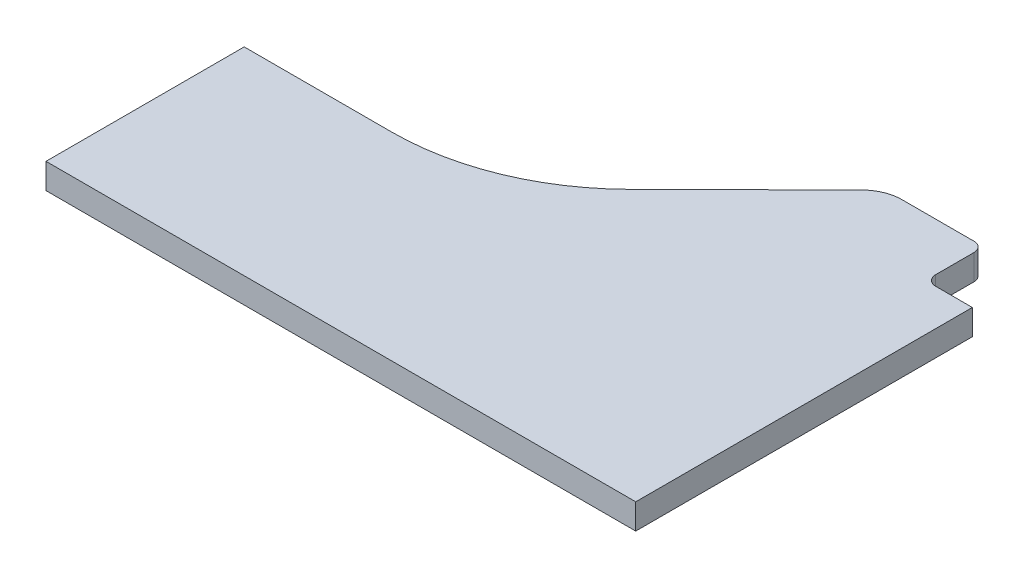
from build123d import *

# Parameters (mm, degrees)
BOSS_EXTRUDE1_DEPTH = 12.7


with BuildPart() as part:
    # Sketch1 → Boss-Extrude1 (new body)
    with BuildSketch(Plane(origin=(0, 0, 0), x_dir=(1, 0, 0), z_dir=(0, 1, 0))):
        with BuildLine():
            Line((0, 0), (295, 0))
            Line((295, 0), (295, 168.379))
            Line((295, 168.379), (276.6155, 168.379))
            ThreePointArc((276.6155, 168.379), (273.079966094, 169.843466094), (271.6155, 173.379))
            Line((271.6155, 173.379), (271.6155, 192.53565981))
            ThreePointArc((271.6155, 192.53565981), (269.906312848, 196.300039015), (265.947279681, 197.490806791))
            Line((265.947279681, 197.490806791), (230.644359426, 197.490806791))
            ThreePointArc((230.644359426, 197.490806791), (223.037191533, 195.987590204), (216.573545734, 191.703906455))
            Line((216.573545734, 191.703906455), (158.153301868, 133.86850202))
            ThreePointArc((158.153301868, 133.86850202), (119.371427078, 108.166399521), (73.728419715, 99.1471))
            Line((73.728419715, 99.1471), (0, 99.1471))
            Line((0, 99.1471), (0, 0))
        make_face()
    extrude(amount=BOSS_EXTRUDE1_DEPTH)


solid = part.part
